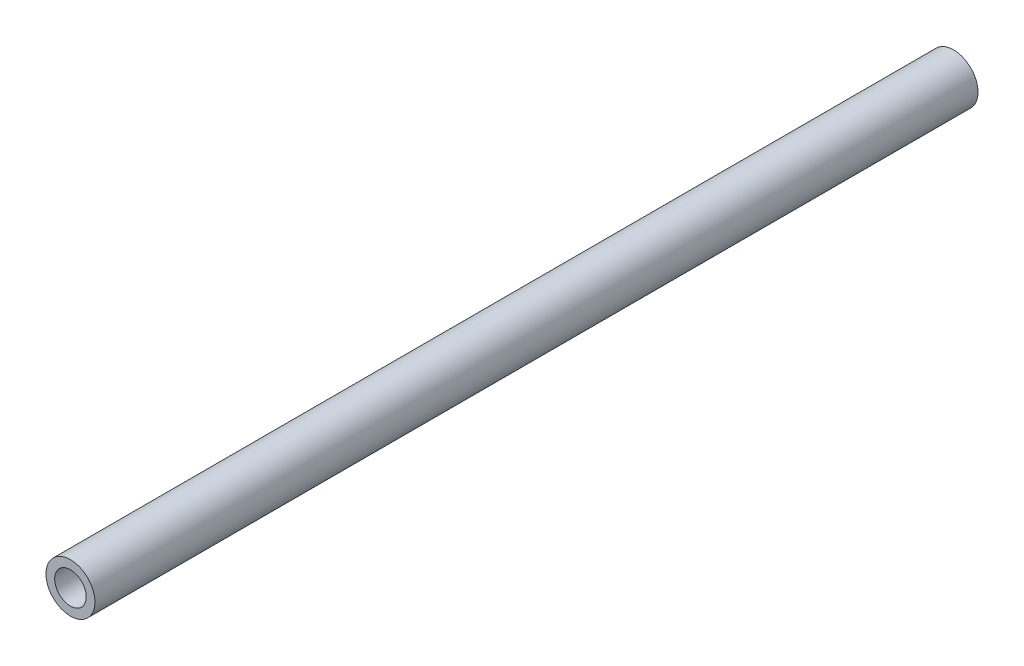
from build123d import *

# Parameters (mm, degrees)
SKETCH1_R           = 0.97
SKETCH1_R_2         = 0.625
BOSS_EXTRUDE1_DEPTH = 35


with BuildPart() as part:
    # Sketch1 → Boss-Extrude1 (new body)
    with BuildSketch(Plane.XY):
        Circle(SKETCH1_R)
        Circle(SKETCH1_R_2, mode=Mode.SUBTRACT)
    extrude(amount=BOSS_EXTRUDE1_DEPTH)


solid = part.part
